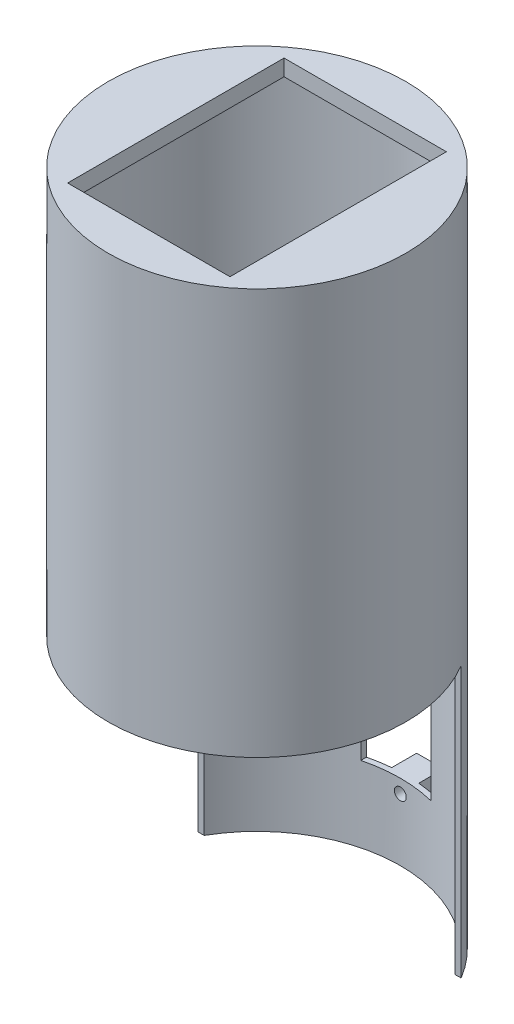
from build123d import *

# Parameters (mm, degrees)
EXTRUDE_1_DEPTH           = 75
EXTRUDE_1_DEPTH_BACK      = 50
SKETCH_1_R                = 27.5
SKETCH_10_W               = 30
SKETCH_10_H               = 40
CUT_EXTRUDE_8_DEPTH       = 45.1
CUT_EXTRUDE_9_DEPTH       = 10
CUT_EXTRUDE_9_DEPTH_BACK  = 113
SKETCH_10_2_W             = 30
SKETCH_10_2_H             = 40
CUT_EXTRUDE_10_DEPTH      = 54
CUT_EXTRUDE_11_DEPTH      = 72
CUT_EXTRUDE_11_DEPTH_BACK = 55
SKETCH_12_R               = 26.5
SKETCH_13_W               = 13
SKETCH_13_H               = 23.5
CUT_EXTRUDE_12_DEPTH      = 54
EXTRUDE_2_DEPTH           = 1
EXTRUDE_2_DEPTH_BACK      = 4
SKETCH_14_W               = 5
SKETCH_14_H               = 5
CUT_EXTRUDE_13_DEPTH      = 4
CUT_EXTRUDE_13_DEPTH_BACK = 5
SKETCH_15_R               = 1.1


with BuildPart() as part:
    # 草圖1 → 填料-伸長1 (new, two sides: drawn at the far end of the back side and taken through both)
    with BuildSketch(Plane(origin=(0, 0, 0), x_dir=(1, 0, 0), z_dir=(0, 1, 0)).offset(-EXTRUDE_1_DEPTH_BACK)):
        Circle(SKETCH_1_R)
    extrude(amount=EXTRUDE_1_DEPTH + EXTRUDE_1_DEPTH_BACK)

    # 草圖10 → 除料-伸長8 (cut)
    with BuildSketch(Plane(origin=(0, 75, 0), x_dir=(1, 0, 0), z_dir=(0, 1, 0))):
        Rectangle(SKETCH_10_W, SKETCH_10_H)
    extrude(amount=-CUT_EXTRUDE_8_DEPTH, mode=Mode.SUBTRACT)

    # 草圖10<2> → 除料-伸長9 (cut, two sides: drawn at the far end of the back side and taken through both)
    with BuildSketch(Plane(origin=(0, 75, 0), x_dir=(1, 0, 0), z_dir=(0, 1, 0)).offset(-CUT_EXTRUDE_9_DEPTH_BACK)):
        Rectangle(SKETCH_10_2_W, SKETCH_10_2_H)
    extrude(amount=CUT_EXTRUDE_9_DEPTH + CUT_EXTRUDE_9_DEPTH_BACK, mode=Mode.SUBTRACT)

    # 草圖11 → 除料-伸長10 (cut)
    with BuildSketch(Plane(origin=(0, 0, 0), x_dir=(1, 0, 0), z_dir=(0, 1, 0))):
        with BuildLine():
            Line((23.587956714, 14.137124816), (-24.13203639, 13.186918505))
            ThreePointArc((-24.13203639, 13.186918505), (0.547474823, -27.494549848), (23.587956714, 14.137124816))
        make_face()
    extrude(amount=-CUT_EXTRUDE_10_DEPTH, mode=Mode.SUBTRACT)

    # 草圖12 → 除料-伸長11 (cut, two sides: drawn at the far end of the back side and taken through both)
    with BuildSketch(Plane(origin=(0, 0, 0), x_dir=(1, 0, 0), z_dir=(0, 1, 0)).offset(-CUT_EXTRUDE_11_DEPTH_BACK)):
        Circle(SKETCH_12_R)
    extrude(amount=CUT_EXTRUDE_11_DEPTH + CUT_EXTRUDE_11_DEPTH_BACK, mode=Mode.SUBTRACT)

    # 草圖13 → 除料-伸長12 (cut)
    with BuildSketch(Plane.XY):
        with Locations((0, -24.25)):
            Rectangle(SKETCH_13_W, SKETCH_13_H)
    extrude(amount=-CUT_EXTRUDE_12_DEPTH, mode=Mode.SUBTRACT)

    # 草圖14 → 填料-伸長2 (add, two sides: drawn at the far end of the back side and taken through both)
    with BuildSketch(Plane.XY.offset(-28).offset(-EXTRUDE_2_DEPTH_BACK)):
        with Locations((0, -38.5)):
            Rectangle(SKETCH_14_W, SKETCH_14_H)
        with Locations((0, -10)):
            Rectangle(SKETCH_14_W, SKETCH_14_H)
    extrude(amount=EXTRUDE_2_DEPTH + EXTRUDE_2_DEPTH_BACK)

    # 草圖15 → 除料-伸長13 (cut, two sides: drawn at the far end of the back side and taken through both)
    with BuildSketch(Plane.XY.offset(-28).offset(-CUT_EXTRUDE_13_DEPTH_BACK)):
        with Locations((0, -10)):
            Circle(SKETCH_15_R)
        with Locations((0, -38.5)):
            Circle(SKETCH_15_R)
    extrude(amount=CUT_EXTRUDE_13_DEPTH + CUT_EXTRUDE_13_DEPTH_BACK, mode=Mode.SUBTRACT)


solid = part.part
